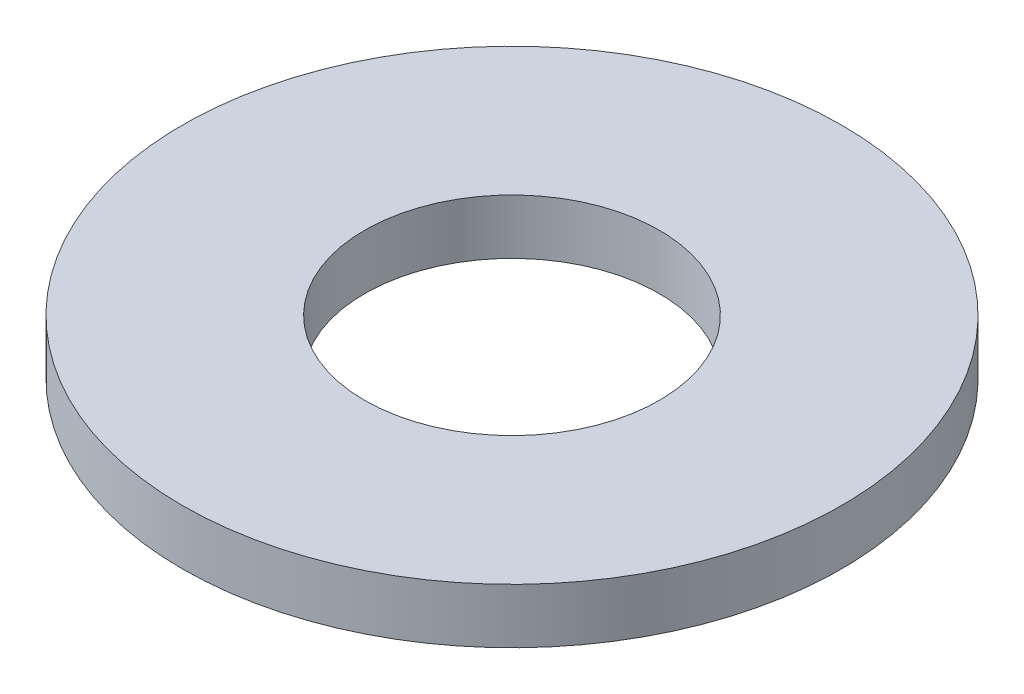
from build123d import *

# Parameters (mm, degrees)
SKETCH1_R           = 9
SKETCH1_R_2         = 4.025
BOSS_EXTRUDE1_DEPTH = 1.5


with BuildPart() as part:
    # Sketch1 → Boss-Extrude1 (new body)
    with BuildSketch(Plane(origin=(0, 0, 0), x_dir=(1, 0, 0), z_dir=(0, 1, 0))):
        Circle(SKETCH1_R)
        Circle(SKETCH1_R_2, mode=Mode.SUBTRACT)
    extrude(amount=BOSS_EXTRUDE1_DEPTH)


solid = part.part
